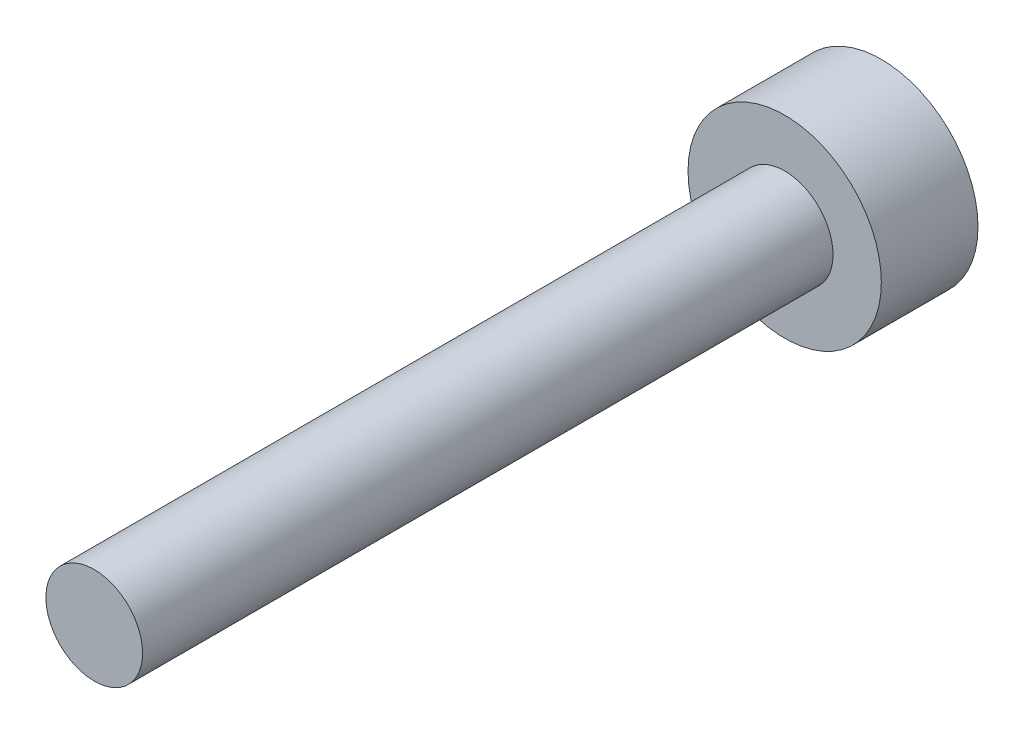
from build123d import *

# Parameters (mm, degrees)
SKETCH_1_R          = 1.4
EXTRUDE_1_DEPTH     = 1.4
SKETCH_2_R          = 0.7
EXTRUDE_2_DEPTH     = 10
CUT_EXTRUDE_1_DEPTH = 1


with BuildPart() as part:
    # 草图1 → 凸台-拉伸1 (new body)
    with BuildSketch(Plane.XY):
        Circle(SKETCH_1_R)
    extrude(amount=EXTRUDE_1_DEPTH)

    # 草图2 → 凸台-拉伸2 (add)
    with BuildSketch(Plane.XY.offset(1.4)):
        Circle(SKETCH_2_R)
    extrude(amount=EXTRUDE_2_DEPTH)

    # 草图3 → 切除-拉伸1 (cut)
    with BuildSketch(Plane(origin=(0, 0, 0), x_dir=(-1, 0, 0), z_dir=(0, 0, -1))):
        Polygon((0, 0.68), (-0.588897275, 0.34), (-0.588897275, -0.34), (0, -0.68), (0.588897275, -0.34), (0.588897275, 0.34), align=None)
    extrude(amount=-CUT_EXTRUDE_1_DEPTH, mode=Mode.SUBTRACT)


solid = part.part
